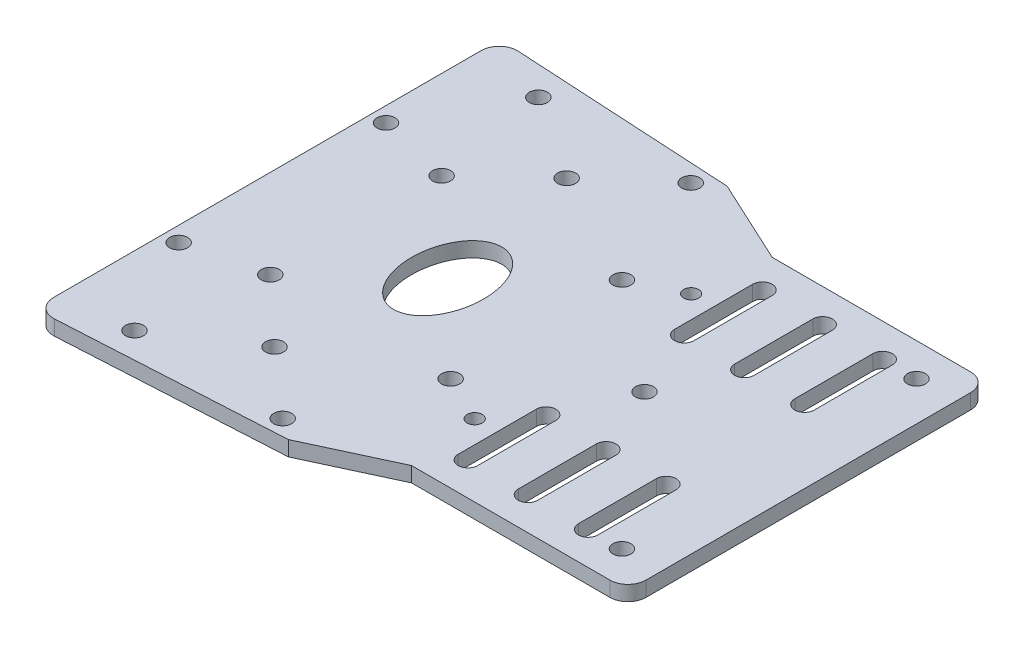
from build123d import *

# Parameters (mm, degrees)
CROQUIS1_R              = 1.5
CROQUIS1_R_2            = 1.25
CROQUIS1_RX             = 9
CROQUIS1_RY             = 6
SALIENTE_EXTRUIR1_DEPTH = 2.5


with BuildPart() as part:
    # Croquis1 → Saliente-Extruir1 (new body)
    with BuildSketch(Plane(origin=(0, 0, 0), x_dir=(1, 0, 0), z_dir=(0, 1, 0))):
        with BuildLine():
            Line((15, -30), (-18, -30))
            Line((-18, -30), (-32, -36.5))
            Line((-32, -36.5), (-68.831516336, -38.571772794))
            ThreePointArc((-68.831516336, -38.571772794), (-71.060891677, -37.756582308), (-72, -35.576507655))
            Line((-72, -35.576507655), (-72, 35.576507655))
            ThreePointArc((-72, 35.576507655), (-71.060891677, 37.756582308), (-68.831516336, 38.571772794))
            Line((-68.831516336, 38.571772794), (-32, 36.5))
            Line((-32, 36.5), (-18, 30))
            Line((-18, 30), (15, 30))
            ThreePointArc((15, 30), (17.121320344, 29.121320344), (18, 27))
            Line((18, 27), (18, -27))
            ThreePointArc((18, -27), (17.121320344, -29.121320344), (15, -30))
        make_face()
        with Locations((11.5, 24.5)):
            Circle(CROQUIS1_R, mode=Mode.SUBTRACT)
        with Locations((11.5, -24.5)):
            Circle(CROQUIS1_R, mode=Mode.SUBTRACT)
        with Locations((-9.25, 0)):
            Circle(CROQUIS1_R, mode=Mode.SUBTRACT)
        with Locations((-19.5, 18)):
            Circle(CROQUIS1_R_2, mode=Mode.SUBTRACT)
        with Locations((-19.5, -18)):
            Circle(CROQUIS1_R_2, mode=Mode.SUBTRACT)
        with Locations((-27.25, -14.25)):
            Circle(CROQUIS1_R, mode=Mode.SUBTRACT)
        with Locations((-27.25, 14.25)):
            Circle(CROQUIS1_R, mode=Mode.SUBTRACT)
        with Locations((-35.5, -33.944899023)):
            Circle(CROQUIS1_R, mode=Mode.SUBTRACT)
        with Locations((-46.5, -24.297446009)):
            Circle(CROQUIS1_R, mode=Mode.SUBTRACT)
        with Locations((-60.5, -33.598382655)):
            Circle(CROQUIS1_R, mode=Mode.SUBTRACT)
        with Locations((-35.5, 33.944899023)):
            Circle(CROQUIS1_R, mode=Mode.SUBTRACT)
        with Locations((-60.5, 33.598382655)):
            Circle(CROQUIS1_R, mode=Mode.SUBTRACT)
        with Locations((-46.5, 24.297446009)):
            Circle(CROQUIS1_R, mode=Mode.SUBTRACT)
        with Locations((-57.25, 14.25)):
            Circle(CROQUIS1_R, mode=Mode.SUBTRACT)
        with Locations((-69.5, 17.25)):
            Circle(CROQUIS1_R, mode=Mode.SUBTRACT)
        with Locations((-57.25, -14.25)):
            Circle(CROQUIS1_R, mode=Mode.SUBTRACT)
        with Locations((-69.5, -17.25)):
            Circle(CROQUIS1_R, mode=Mode.SUBTRACT)
        with Locations(Location((-42, 0), (0, 0, -90))):
            Ellipse(CROQUIS1_RX, CROQUIS1_RY, mode=Mode.SUBTRACT)
        with BuildLine():
            Line((7.5, 24.5), (7.5, 11.5))
            ThreePointArc((7.5, 11.5), (5.875, 9.875), (4.25, 11.5))
            Line((4.25, 11.5), (4.25, 24.5))
            ThreePointArc((4.25, 24.5), (5.875, 26.125), (7.5, 24.5))
        make_face(mode=Mode.SUBTRACT)
        with BuildLine():
            Line((7.5, -24.5), (7.5, -11.5))
            ThreePointArc((7.5, -11.5), (5.875, -9.875), (4.25, -11.5))
            Line((4.25, -11.5), (4.25, -24.5))
            ThreePointArc((4.25, -24.5), (5.875, -26.125), (7.5, -24.5))
        make_face(mode=Mode.SUBTRACT)
        with BuildLine():
            Line((-2.5, 24.5), (-2.5, 11.5))
            ThreePointArc((-2.5, 11.5), (-4.125, 9.875), (-5.75, 11.5))
            Line((-5.75, 11.5), (-5.75, 24.5))
            ThreePointArc((-5.75, 24.5), (-4.125, 26.125), (-2.5, 24.5))
        make_face(mode=Mode.SUBTRACT)
        with BuildLine():
            Line((-12.5, 24.5), (-12.5, 11.5))
            ThreePointArc((-12.5, 11.5), (-14.125, 9.875), (-15.75, 11.5))
            Line((-15.75, 11.5), (-15.75, 24.5))
            ThreePointArc((-15.75, 24.5), (-14.125, 26.125), (-12.5, 24.5))
        make_face(mode=Mode.SUBTRACT)
        with BuildLine():
            Line((-2.5, -24.5), (-2.5, -11.5))
            ThreePointArc((-2.5, -11.5), (-4.125, -9.875), (-5.75, -11.5))
            Line((-5.75, -11.5), (-5.75, -24.5))
            ThreePointArc((-5.75, -24.5), (-4.125, -26.125), (-2.5, -24.5))
        make_face(mode=Mode.SUBTRACT)
        with BuildLine():
            Line((-12.5, -24.5), (-12.5, -11.5))
            ThreePointArc((-12.5, -11.5), (-14.125, -9.875), (-15.75, -11.5))
            Line((-15.75, -11.5), (-15.75, -24.5))
            ThreePointArc((-15.75, -24.5), (-14.125, -26.125), (-12.5, -24.5))
        make_face(mode=Mode.SUBTRACT)
    extrude(amount=SALIENTE_EXTRUIR1_DEPTH)


solid = part.part
